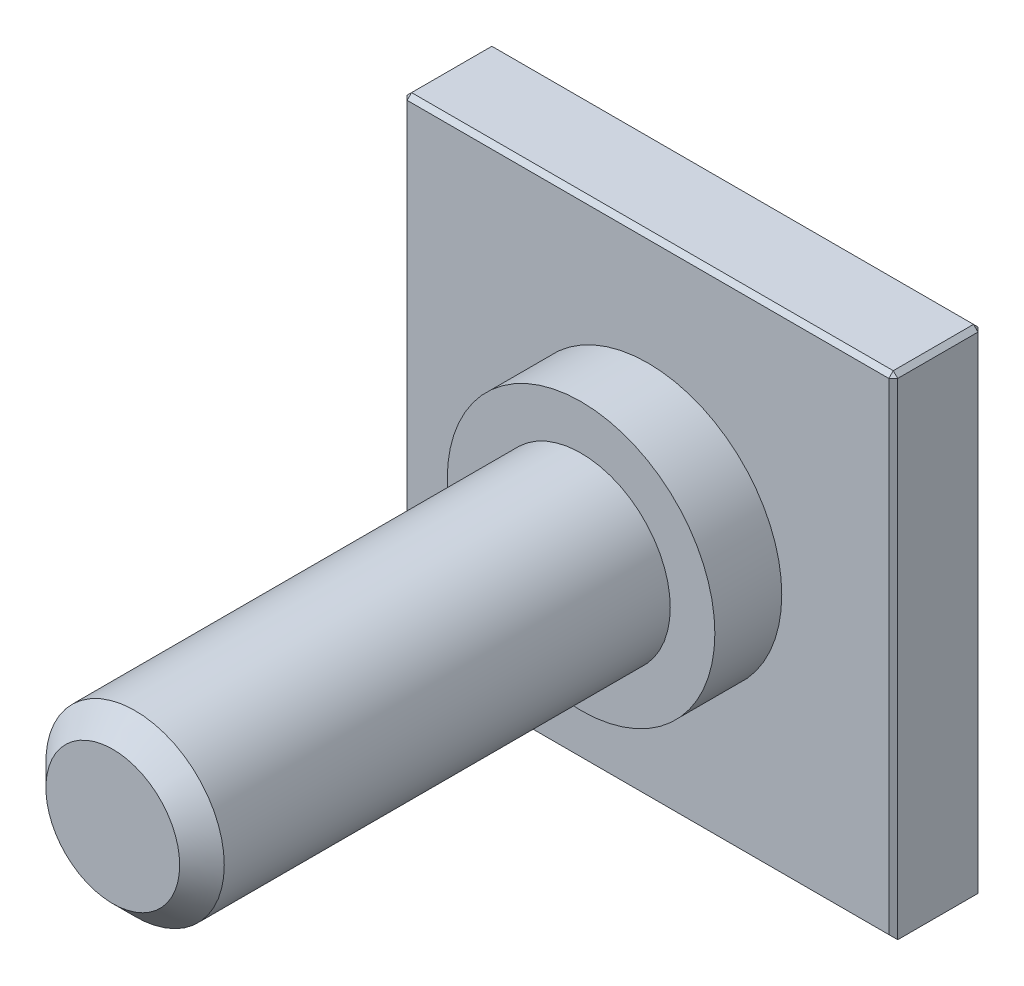
from build123d import *

# Parameters (mm, degrees)
SKETCH1_W           = 11
SKETCH1_H           = 11
BOSS_EXTRUDE1_DEPTH = 2
SKETCH2_R           = 2
BOSS_EXTRUDE2_DEPTH = 12
CHAMFER1_SIZE       = 0.1
SKETCH3_R           = 3
BOSS_EXTRUDE3_DEPTH = 1.5
CHAMFER2_SIZE       = 0.5


with BuildPart() as part:
    # Sketch1 → Boss-Extrude1 (new body)
    with BuildSketch(Plane.XY):
        Rectangle(SKETCH1_W, SKETCH1_H)
    extrude(amount=BOSS_EXTRUDE1_DEPTH)

    # Sketch2 → Boss-Extrude2 (add)
    with BuildSketch(Plane.XY.offset(2)):
        Circle(SKETCH2_R)
    extrude(amount=BOSS_EXTRUDE2_DEPTH)

    # Chamfer1
    chamfer1_edges = [part.edges().sort_by_distance(p)[0] for p in [
        (-5.5, 0, 2),
        (0, -5.5, 2),
        (5.5, 0, 2),
        (0, -5.5, 0),
        (-5.5, 0, 0),
        (0, 5.5, 0),
        (5.5, 0, 0),
        (0, 5.5, 2),
        (-5.5, 5.5, 1),
        (5.5, 5.5, 1),
    ]]
    chamfer(chamfer1_edges, length=CHAMFER1_SIZE)

    # Sketch3 → Boss-Extrude3 (add)
    with BuildSketch(Plane.XY.offset(2)):
        Circle(SKETCH3_R)
    extrude(amount=BOSS_EXTRUDE3_DEPTH)

    # Chamfer2
    chamfer2_edges = [part.edges().sort_by_distance(p)[0] for p in [
        (-2, 0, 14),
    ]]
    chamfer(chamfer2_edges, length=CHAMFER2_SIZE)


solid = part.part
